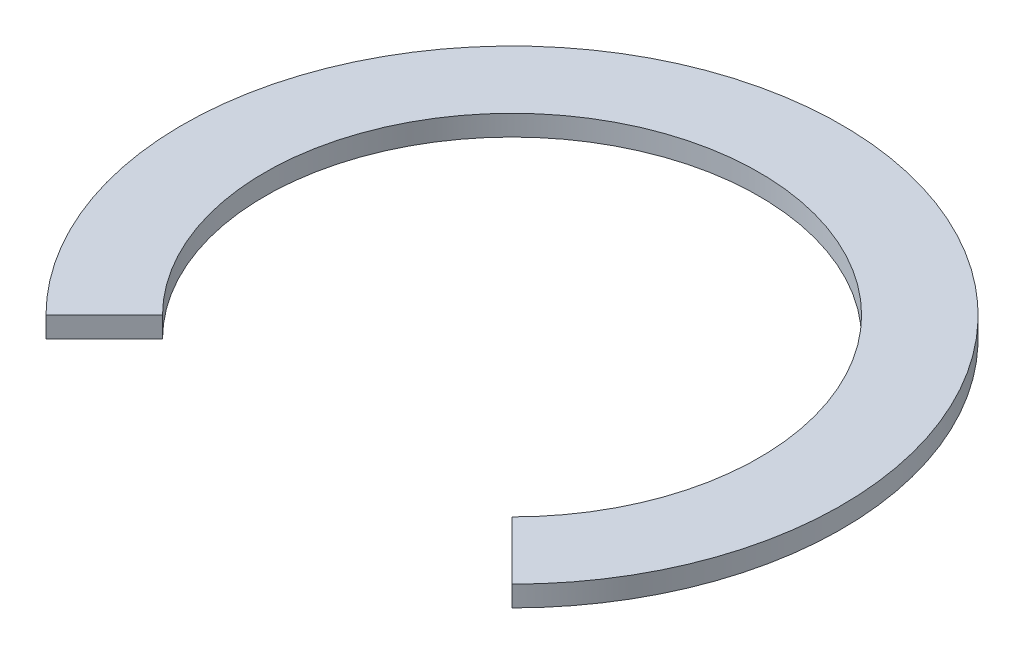
from build123d import *

# Parameters (mm, degrees)
SKETCH2_R                    = 12.7
BOSS_EXTRUDE1_DEPTH          = 0.79375
SKETCH3_R                    = 9.525
CUT_EXTRUDE1_DEPTH           = 1.79375
SKETCH4_W                    = 22.318168974
SKETCH4_H                    = 8.357131245
CUT_REVOLVE1_ANGLE           = 45
CUT_REVOLVE1_OTHER_WAY_ANGLE = 45


with BuildPart() as part:
    # Sketch2 → Boss-Extrude1 (new body)
    with BuildSketch(Plane(origin=(0, 0, 0), x_dir=(1, 0, 0), z_dir=(0, 1, 0))):
        Circle(SKETCH2_R)
    extrude(amount=BOSS_EXTRUDE1_DEPTH)

    # Sketch3 → Cut-Extrude1 (cut, through all)
    with BuildSketch(Plane(origin=(0, 0.79375, 0), x_dir=(1, 0, 0), z_dir=(0, 1, 0))):
        Circle(SKETCH3_R)
    extrude(amount=-CUT_EXTRUDE1_DEPTH, mode=Mode.SUBTRACT)

    # Sketch4 → Cut-Revolve1 (revolve, cut)
    with BuildSketch(Plane(origin=(0, 0, 0), x_dir=(0, 0, -1), z_dir=(1, 0, 0))):
        with Locations((-11.159084487, 3.258563731)):
            Rectangle(SKETCH4_W, SKETCH4_H)
    revolve(axis=Axis((0, -0.920001892, 0), (0, 1, 0)), revolution_arc=CUT_REVOLVE1_ANGLE, mode=Mode.SUBTRACT)

    # Sketch4 → Cut-Revolve1 other way (revolve, cut)
    with BuildSketch(Plane(origin=(0, 0, 0), x_dir=(0, 0, -1), z_dir=(1, 0, 0))):
        with Locations((-11.159084487, 3.258563731)):
            Rectangle(SKETCH4_W, SKETCH4_H)
    revolve(axis=Axis((0, -0.920001892, 0), (0, -1, 0)), revolution_arc=CUT_REVOLVE1_OTHER_WAY_ANGLE, mode=Mode.SUBTRACT)


solid = part.part
